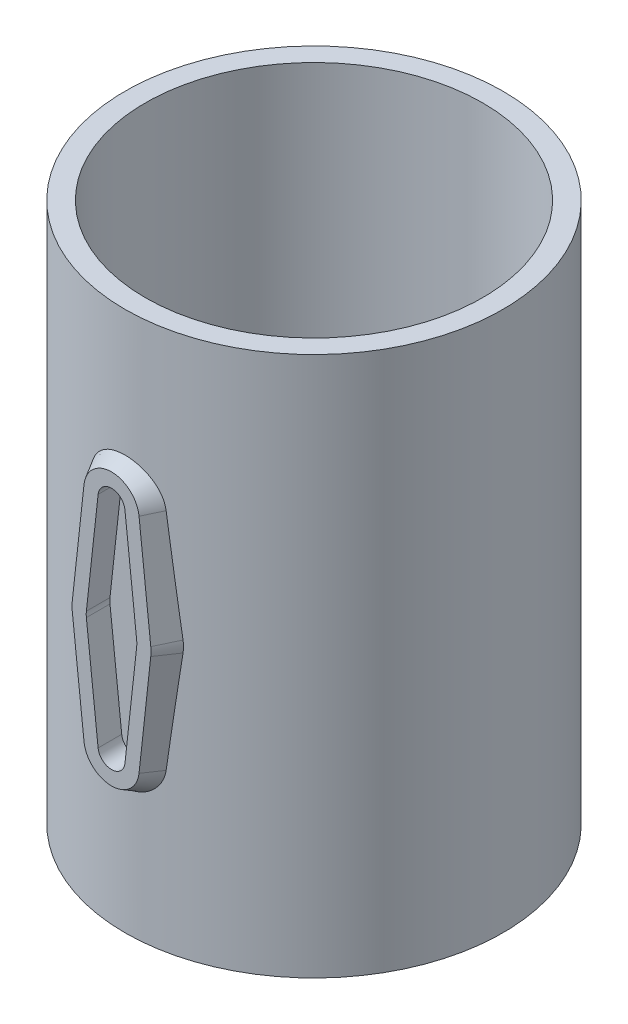
from build123d import *

# Parameters (mm, degrees)
SKETCH1_R                = 28
SKETCH1_R_2              = 25
BOSS_EXTRUDE1_DEPTH      = 80
CUT_EXTRUDE3_DEPTH       = 101.768298586
EXTRUDE_THIN2_DEPTH      = 3.5
EXTRUDE_THIN3_REACH      = 104.703
EXTRUDE_THIN3_END_RADIUS = 28
EXTRUDE_THIN3_DRAFT      = 30
SKETCH10_W               = 7
SKETCH10_H               = 7
CUT_EXTRUDE4_DEPTH       = 3


with BuildPart() as part:
    # Sketch1 → Boss-Extrude1 (new body)
    with BuildSketch(Plane(origin=(0, 0, 0), x_dir=(1, 0, 0), z_dir=(0, 1, 0))):
        with Locations(Location((0, 0, 0), (0, 0, 270))):
            Circle(SKETCH1_R)
        with Locations(Location((0, 0, 0), (0, 0, 270))):
            Circle(SKETCH1_R_2, mode=Mode.SUBTRACT)
    extrude(amount=BOSS_EXTRUDE1_DEPTH)

    # Sketch6 → Cut-Extrude3 (cut, through all)
    with BuildSketch(Plane.XY.offset(26.5)):
        with BuildLine():
            Line((-3.727642468, 40.408878505), (-1.988075983, 56.268068536))
            ThreePointArc((-1.988075983, 56.268068536), (0, 58.05), (1.988075983, 56.268068536))
            Line((1.988075983, 56.268068536), (3.727642468, 40.408878505))
            ThreePointArc((3.727642468, 40.408878505), (3.75, 40), (3.727642468, 39.591121495))
            Line((3.727642468, 39.591121495), (1.988075983, 23.731931464))
            ThreePointArc((1.988075983, 23.731931464), (0, 21.95), (-1.988075983, 23.731931464))
            Line((-1.988075983, 23.731931464), (-3.727642468, 39.591121495))
            ThreePointArc((-3.727642468, 39.591121495), (-3.75, 40), (-3.727642468, 40.408878505))
        make_face()
    extrude(amount=CUT_EXTRUDE3_DEPTH, mode=Mode.SUBTRACT)

    # Sketch7 → Extrude-Thin2 (add)
    with BuildSketch(Plane.XY.offset(26.5)):
        with BuildLine():
            Line((5.715718451, 40.62694704), (3.976151966, 56.486137072))
            ThreePointArc((3.976151966, 56.486137072), (0, 60.05), (-3.976151966, 56.486137072))
            Line((-3.976151966, 56.486137072), (-5.715718451, 40.62694704))
            ThreePointArc((-5.715718451, 40.62694704), (-5.75, 40), (-5.715718451, 39.37305296))
            Line((-5.715718451, 39.37305296), (-3.976151966, 23.513862928))
            ThreePointArc((-3.976151966, 23.513862928), (0, 19.95), (3.976151966, 23.513862928))
            Line((3.976151966, 23.513862928), (5.715718451, 39.37305296))
            ThreePointArc((5.715718451, 39.37305296), (5.75, 40), (5.715718451, 40.62694704))
        make_face()
        with BuildLine():
            Line((3.727642468, 40.408878505), (1.988075983, 56.268068536))
            ThreePointArc((1.988075983, 56.268068536), (0, 58.05), (-1.988075983, 56.268068536))
            Line((-1.988075983, 56.268068536), (-3.727642468, 40.408878505))
            ThreePointArc((-3.727642468, 40.408878505), (-3.75, 40), (-3.727642468, 39.591121495))
            Line((-3.727642468, 39.591121495), (-1.988075983, 23.731931464))
            ThreePointArc((-1.988075983, 23.731931464), (0, 21.95), (1.988075983, 23.731931464))
            Line((1.988075983, 23.731931464), (3.727642468, 39.591121495))
            ThreePointArc((3.727642468, 39.591121495), (3.75, 40), (3.727642468, 40.408878505))
        make_face(mode=Mode.SUBTRACT)
    extrude(amount=EXTRUDE_THIN2_DEPTH)

    # Extrude-Thin3: up to this cylinder (the profile starts outside it)
    extrude_thin3_end = Plane(origin=(0, 48.56287, 0), z_dir=(0, -1, 0)) * Cylinder(EXTRUDE_THIN3_END_RADIUS, 266.406, mode=Mode.PRIVATE)



with BuildPart() as extrude_thin3_long_prism_1:
    # Sketch9 → Extrude-Thin3 (the long prism of profile 1, to be tilted and cut off)
    with BuildSketch(Plane.XY.offset(30)):
        with BuildLine():
            Line((-4.075555765, 56.497040498), (-5.81512225, 40.637850467))
            ThreePointArc((-5.81512225, 40.637850467), (-5.85, 40), (-5.81512225, 39.362149533))
            Line((-5.81512225, 39.362149533), (-4.075555765, 23.502959502))
            ThreePointArc((-4.075555765, 23.502959502), (0, 19.85), (4.075555765, 23.502959502))
            Line((4.075555765, 23.502959502), (5.81512225, 39.362149533))
            ThreePointArc((5.81512225, 39.362149533), (5.85, 40), (5.81512225, 40.637850467))
            Line((5.81512225, 40.637850467), (4.075555765, 56.497040498))
            ThreePointArc((4.075555765, 56.497040498), (0, 60.15), (-4.075555765, 56.497040498))
        make_face()
        with BuildLine():
            Line((-3.976151966, 56.486137072), (-5.715718451, 40.62694704))
            ThreePointArc((-5.715718451, 40.62694704), (-5.75, 40), (-5.715718451, 39.37305296))
            Line((-5.715718451, 39.37305296), (-3.976151966, 23.513862928))
            ThreePointArc((-3.976151966, 23.513862928), (0, 19.95), (3.976151966, 23.513862928))
            Line((3.976151966, 23.513862928), (5.715718451, 39.37305296))
            ThreePointArc((5.715718451, 39.37305296), (5.75, 40), (5.715718451, 40.62694704))
            Line((5.715718451, 40.62694704), (3.976151966, 56.486137072))
            ThreePointArc((3.976151966, 56.486137072), (0, 60.05), (-3.976151966, 56.486137072))
        make_face(mode=Mode.SUBTRACT)
    extrude(amount=-EXTRUDE_THIN3_REACH)
    extrude_thin3_tool1_sides = [extrude_thin3_long_prism_1.faces().sort_by_distance(p)[0] for p in [
        (4.945339007, 48.567445483, -22.3515),
        (0, 60.15, -22.3515),
        (-4.945339007, 48.567445483, -22.3515),
        (-5.85, 40, -22.3515),
        (-4.945339007, 31.432554517, -22.3515),
        (0, 19.85, -22.3515),
        (4.945339007, 31.432554517, -22.3515),
        (5.85, 40, -22.3515),
        (4.845935208, 48.556542056, -22.3515),
        (5.75, 40, -22.3515),
        (4.845935208, 31.443457944, -22.3515),
        (0, 19.95, -22.3515),
        (-4.845935208, 31.443457944, -22.3515),
        (-5.75, 40, -22.3515),
        (-4.845935208, 48.556542056, -22.3515),
        (0, 60.05, -22.3515),
    ]]
    draft(extrude_thin3_tool1_sides, Plane.XY.offset(30), EXTRUDE_THIN3_DRAFT)  # the draft: side faces tilted about the start plane


with BuildPart() as part_1:
    add(part.part)
    extrude_thin3_tool1 = extrude_thin3_long_prism_1.part - extrude_thin3_end
    add(extrude_thin3_tool1.solids().sort_by_distance((4.903625, 48.56287, 30))[0])

    # Sketch10 → Cut-Extrude4 (cut)
    with BuildSketch(Plane.XY.offset(-26.5)):
        with Locations((0, 40)):
            Rectangle(SKETCH10_W, SKETCH10_H)
    extrude(amount=-CUT_EXTRUDE4_DEPTH, mode=Mode.SUBTRACT)


solid = part_1.part
